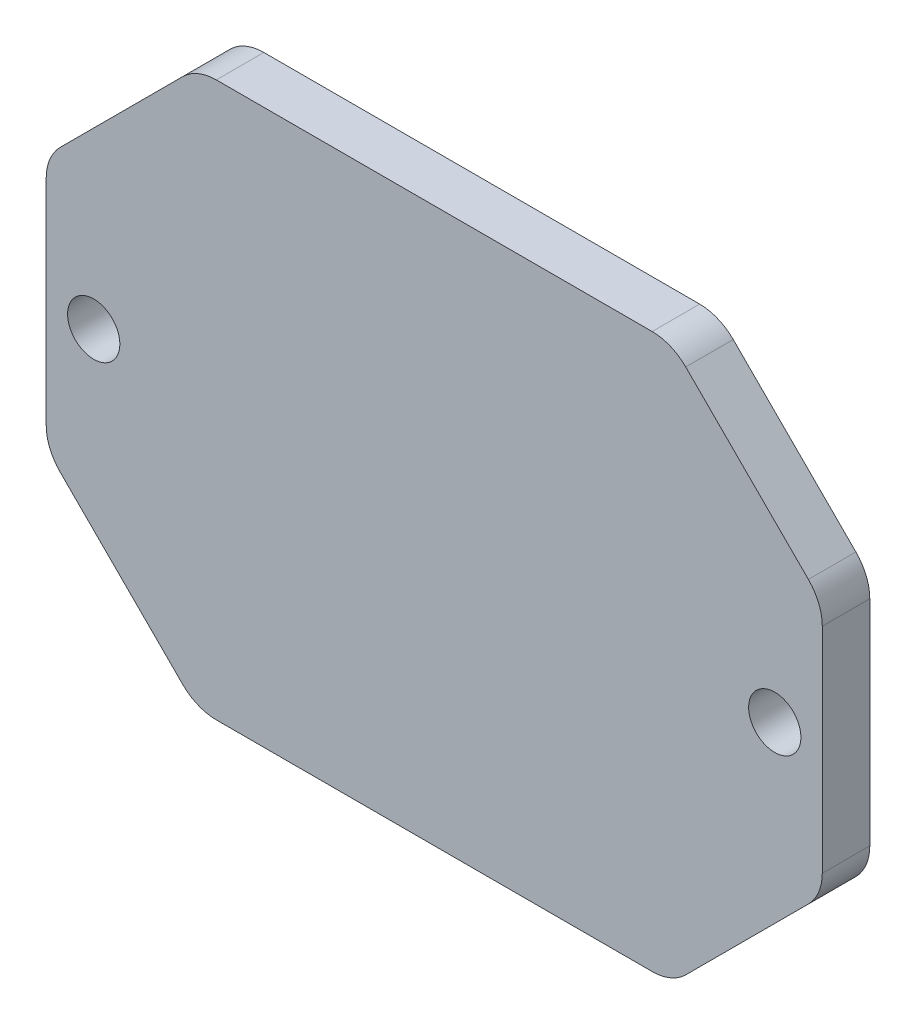
from build123d import *

# Parameters (mm, degrees)
SKETCH_1_W          = 49
SKETCH_1_H          = 34.996183206
EXTRUDE_1_DEPTH     = 3
CHAMFER_1_SIZE      = 9.5
FILLET_1_R          = 3
SKETCH_2_R          = 1.65
CUT_EXTRUDE_1_DEPTH = 4


with BuildPart() as part:
    # 草图1 → 凸台-拉伸1 (new body)
    with BuildSketch(Plane.XY):
        Rectangle(SKETCH_1_W, SKETCH_1_H)
    extrude(amount=EXTRUDE_1_DEPTH)

    # 倒角1
    chamfer_1_edges = [part.edges().sort_by_distance(p)[0] for p in [
        (24.5, -17.498091603, 1.5),
        (-24.5, -17.498091603, 1.5),
        (-24.5, 17.498091603, 1.5),
        (24.5, 17.498091603, 1.5),
    ]]
    chamfer(chamfer_1_edges, length=CHAMFER_1_SIZE)

    # 圆角1
    fillet_1_edges = [part.edges().sort_by_distance(p)[0] for p in [
        (-24.5, -7.998091603, 1.5),
        (-24.5, 7.998091603, 1.5),
        (15, 17.498091603, 1.5),
        (-15, 17.498091603, 1.5),
        (15, -17.498091603, 1.5),
        (-15, -17.498091603, 1.5),
        (24.5, 7.998091603, 1.5),
        (24.5, -7.998091603, 1.5),
    ]]
    fillet(fillet_1_edges, radius=FILLET_1_R)

    # 草图2 → 切除-拉伸1 (cut, through all)
    with BuildSketch(Plane.XY.offset(3)):
        with Locations((-21.5, 0)):
            Circle(SKETCH_2_R)
        with Locations((21.5, 0)):
            Circle(SKETCH_2_R)
    extrude(amount=-CUT_EXTRUDE_1_DEPTH, mode=Mode.SUBTRACT)


solid = part.part
